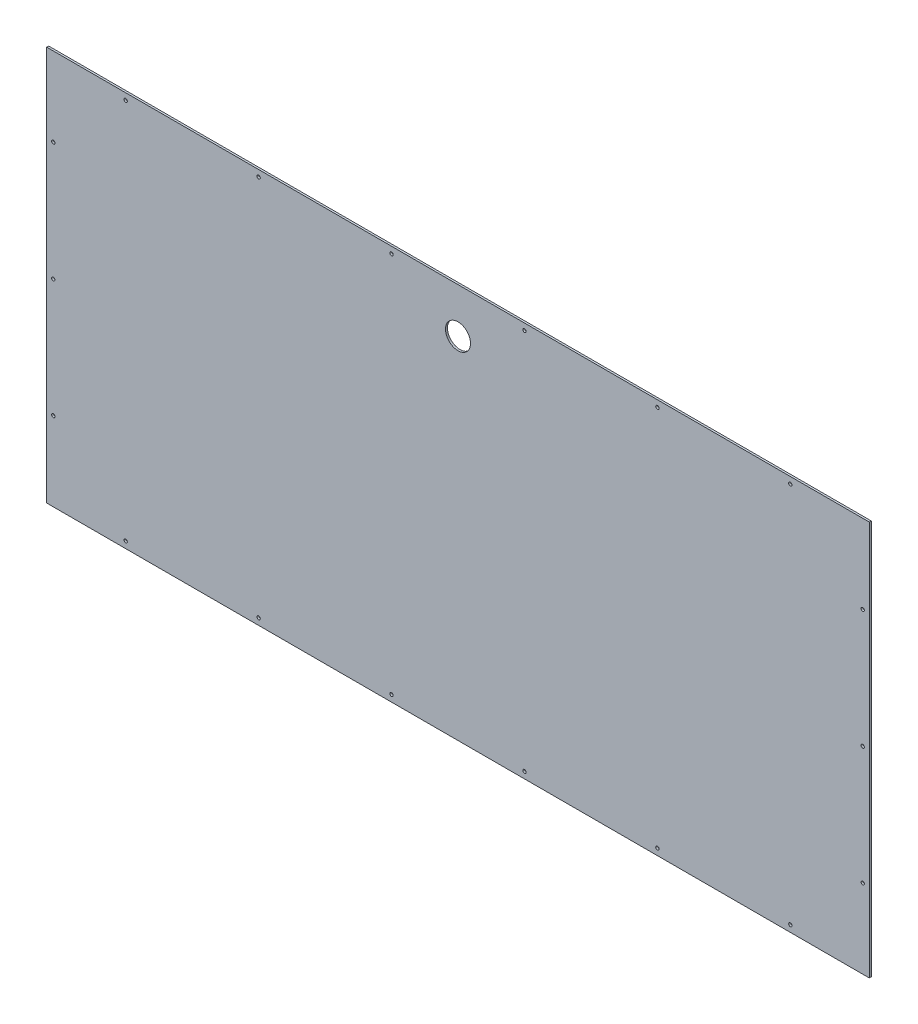
from build123d import *

# Parameters (mm, degrees)
SKETCH1_W           = 1250
SKETCH1_H           = 600
SKETCH1_R           = 2.55
SKETCH1_R_2         = 19
BOSS_EXTRUDE1_DEPTH = 3


with BuildPart() as part:
    # Sketch1 → Boss-Extrude1 (new body)
    with BuildSketch(Plane.XY):
        Rectangle(SKETCH1_W, SKETCH1_H)
        with Locations((303, 290)):
            Circle(SKETCH1_R, mode=Mode.SUBTRACT)
        with Locations((101, 290)):
            Circle(SKETCH1_R, mode=Mode.SUBTRACT)
        with Locations((-101, 290)):
            Circle(SKETCH1_R, mode=Mode.SUBTRACT)
        with Locations((-303, 290)):
            Circle(SKETCH1_R, mode=Mode.SUBTRACT)
        with Locations((505, 290)):
            Circle(SKETCH1_R, mode=Mode.SUBTRACT)
        with Locations((505, -290)):
            Circle(SKETCH1_R, mode=Mode.SUBTRACT)
        with Locations((-505, 290)):
            Circle(SKETCH1_R, mode=Mode.SUBTRACT)
        with Locations((303, -290)):
            Circle(SKETCH1_R, mode=Mode.SUBTRACT)
        with Locations((101, -290)):
            Circle(SKETCH1_R, mode=Mode.SUBTRACT)
        with Locations((-101, -290)):
            Circle(SKETCH1_R, mode=Mode.SUBTRACT)
        with Locations((615, 180)):
            Circle(SKETCH1_R, mode=Mode.SUBTRACT)
        with Locations((-615, 180)):
            Circle(SKETCH1_R, mode=Mode.SUBTRACT)
        with Locations((-615, 0)):
            Circle(SKETCH1_R, mode=Mode.SUBTRACT)
        with Locations((-615, -180)):
            Circle(SKETCH1_R, mode=Mode.SUBTRACT)
        with Locations((-303, -290)):
            Circle(SKETCH1_R, mode=Mode.SUBTRACT)
        with Locations((615, 0)):
            Circle(SKETCH1_R, mode=Mode.SUBTRACT)
        with Locations((615, -180)):
            Circle(SKETCH1_R, mode=Mode.SUBTRACT)
        with Locations((-505, -290)):
            Circle(SKETCH1_R, mode=Mode.SUBTRACT)
        with Locations((0, 232)):
            Circle(SKETCH1_R_2, mode=Mode.SUBTRACT)
    extrude(amount=BOSS_EXTRUDE1_DEPTH)


solid = part.part
